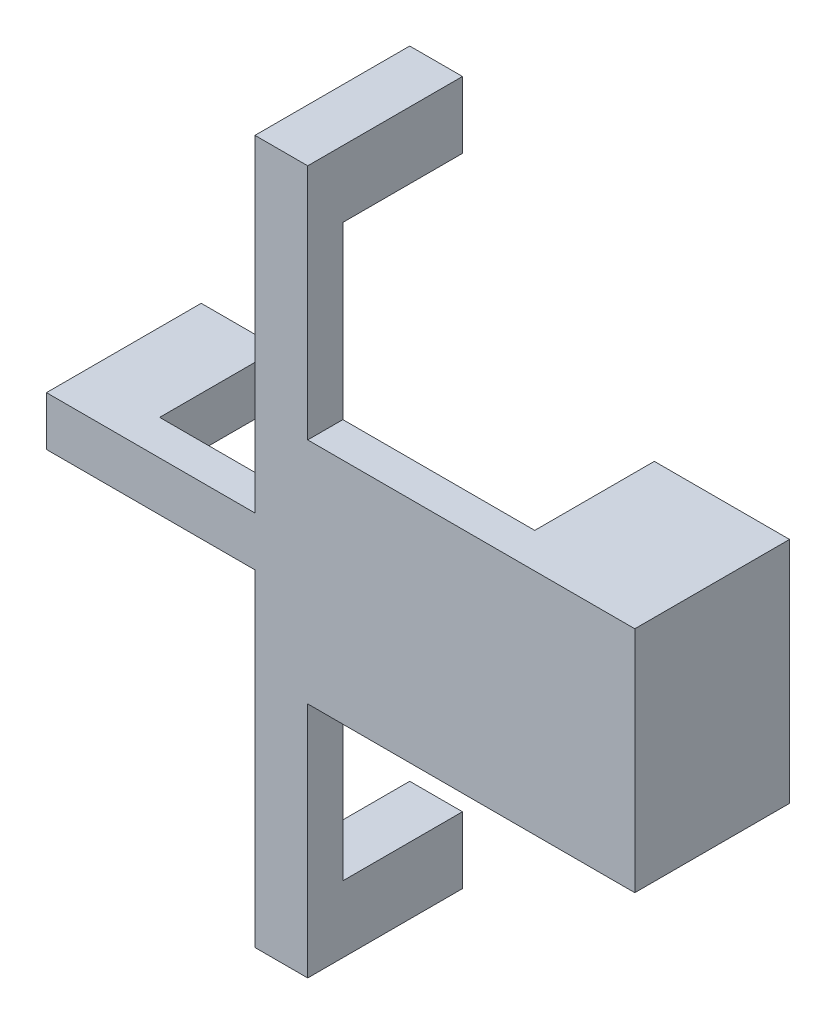
from build123d import *

# Parameters (mm, degrees)
SKETCH_1_W        = 4.436635541
SKETCH_1_H        = 2.8
EXTRUDE_1_DEPTH   = 8.8
SKETCH_1_W_2      = 7.689400099
SKETCH_1_H_2      = 13
EXTRUDE_1_2_DEPTH = 8.8
SKETCH_1_W_3      = 3
SKETCH_1_H_3      = 3.788471525
EXTRUDE_1_3_DEPTH = 8.8
EXTRUDE_1_4_DEPTH = 8.8
EXTRUDE_2_DEPTH   = 2


with BuildPart() as part:
    # ｽｹｯﾁ1 → ﾎﾞｽ - 押し出し1 (new body)
    with BuildSketch(Plane.XY):
        with Locations((-12.63934737, -6.5)):
            Rectangle(SKETCH_1_W, SKETCH_1_H)
    extrude(amount=-EXTRUDE_1_DEPTH)


with BuildPart() as body_2:
    # ｽｹｯﾁ1 → Extrude 1 2 (new body)
    with BuildSketch(Plane.XY):
        with Locations((14.755299951, -6.5)):
            Rectangle(SKETCH_1_W_2, SKETCH_1_H_2)
    extrude(amount=-EXTRUDE_1_2_DEPTH)



with BuildPart() as body_3:
    # ｽｹｯﾁ1 → Extrude 1 3 (new body)
    with BuildSketch(Plane.XY):
        with Locations((-1.5, 11.605764238)):
            Rectangle(SKETCH_1_W_3, SKETCH_1_H_3)
    extrude(amount=-EXTRUDE_1_3_DEPTH)


with BuildPart() as body_4:
    # ｽｹｯﾁ1 → Extrude 1 4 (new body)
    with BuildSketch(Plane.XY):
        with Locations((-1.5, -24.605764238)):
            Rectangle(SKETCH_1_W_3, SKETCH_1_H_3)
    extrude(amount=-EXTRUDE_1_4_DEPTH)


with BuildPart() as body_2_1:
    add(body_2.part)

    add(body_3.part)  # ﾎﾞｽ - 押し出し2 merges body 3

    add(body_4.part)  # ﾎﾞｽ - 押し出し2 merges body 4
    # ｽｹｯﾁ2 → ﾎﾞｽ - 押し出し2 (add)
    with BuildSketch(Plane.XY):
        Polygon((0, -13), (18.6, -13), (18.6, 0), (0, 0), (0, 13.5), (-3, 13.5), (-3, -5.1), (-14.85766514, -5.1), (-14.85766514, -7.9), (-3, -7.9), (-3, -26.5), (0, -26.5), align=None)
    extrude(amount=-EXTRUDE_2_DEPTH)


with BuildPart() as part_1:
    add(part.part)

    # Combine 1: union body 2
    add(body_2_1.part)


solid = part_1.part
